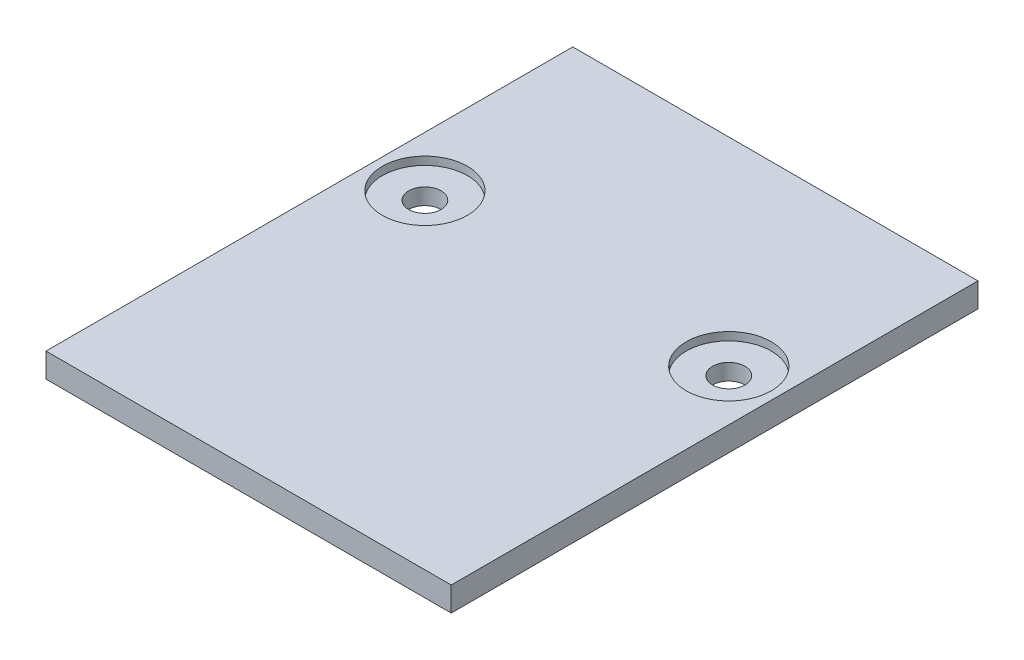
from build123d import *

# Parameters (mm, degrees)
SKETCH1_W           = 100
SKETCH1_H           = 130
BOSS_EXTRUDE1_DEPTH = 6
SKETCH3_R           = 4
CUT_EXTRUDE2_DEPTH  = 7
SKETCH4_R           = 10.5
CUT_EXTRUDE3_DEPTH  = 2


with BuildPart() as part:
    # Sketch1 → Boss-Extrude1 (new body)
    with BuildSketch(Plane(origin=(0, 0, 0), x_dir=(1, 0, 0), z_dir=(0, 1, 0))):
        Rectangle(SKETCH1_W, SKETCH1_H)
    extrude(amount=BOSS_EXTRUDE1_DEPTH)

    # Sketch3 → Cut-Extrude2 (cut, through all)
    with BuildSketch(Plane(origin=(0, 6, 0), x_dir=(1, 0, 0), z_dir=(0, 1, 0))):
        with Locations((-37.5, 16)):
            Circle(SKETCH3_R)
        with Locations((37.5, 16)):
            Circle(SKETCH3_R)
    extrude(amount=-CUT_EXTRUDE2_DEPTH, mode=Mode.SUBTRACT)

    # Sketch4 → Cut-Extrude3 (cut)
    with BuildSketch(Plane(origin=(0, 6, 0), x_dir=(1, 0, 0), z_dir=(0, 1, 0))):
        with Locations((37.5, 16)):
            Circle(SKETCH4_R)
        with Locations((-37.5, 16)):
            Circle(SKETCH4_R)
    extrude(amount=-CUT_EXTRUDE3_DEPTH, mode=Mode.SUBTRACT)


solid = part.part
